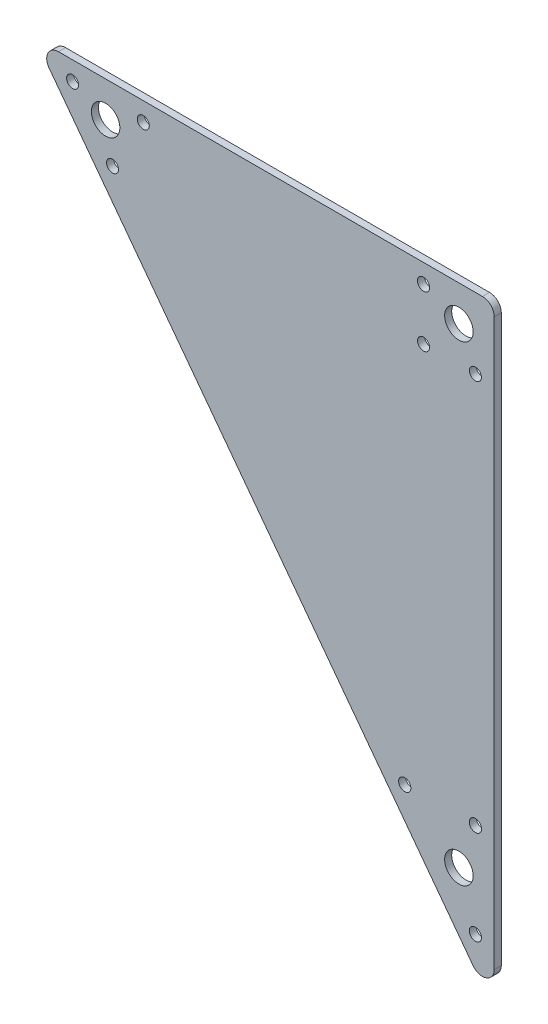
from build123d import *

# Parameters (mm, degrees)
SKETCH_2_R      = 6.05
SKETCH_2_R_2    = 2.55
SKETCH_2_R_3    = 2.6
EXTRUDE_1_DEPTH = 3
FILLET_1_R      = 5


with BuildPart() as part:
    # 草图2 → 凸台-拉伸1 (new body)
    with BuildSketch(Plane.XY):
        Polygon((-180, 15), (15, 15), (15, -245), align=None)
        Circle(SKETCH_2_R, mode=Mode.SUBTRACT)
        with Locations((-150, 0)):
            Circle(SKETCH_2_R, mode=Mode.SUBTRACT)
        with Locations((0, -200)):
            Circle(SKETCH_2_R, mode=Mode.SUBTRACT)
        with Locations((-164, 7)):
            Circle(SKETCH_2_R_2, mode=Mode.SUBTRACT)
        with Locations((-134, 7)):
            Circle(SKETCH_2_R_2, mode=Mode.SUBTRACT)
        with Locations((-147.04893552, -15.601419306)):
            Circle(SKETCH_2_R_2, mode=Mode.SUBTRACT)
        with Locations((-15, 7)):
            Circle(SKETCH_2_R_3, mode=Mode.SUBTRACT)
        with Locations((7, -15)):
            Circle(SKETCH_2_R_2, mode=Mode.SUBTRACT)
        with Locations((7, -221)):
            Circle(SKETCH_2_R_3, mode=Mode.SUBTRACT)
        with Locations((-23, -181)):
            Circle(SKETCH_2_R_3, mode=Mode.SUBTRACT)
        with Locations((7, -181)):
            Circle(SKETCH_2_R_3, mode=Mode.SUBTRACT)
        with Locations((-15, -15)):
            Circle(SKETCH_2_R_2, mode=Mode.SUBTRACT)
    extrude(amount=EXTRUDE_1_DEPTH)

    # 圆角1
    fillet_1_edges = [part.edges().sort_by_distance(p)[0] for p in [
        (-180, 15, 1.5),
        (15, 15, 1.5),
        (15, -245, 1.5),
    ]]
    fillet(fillet_1_edges, radius=FILLET_1_R)


solid = part.part
